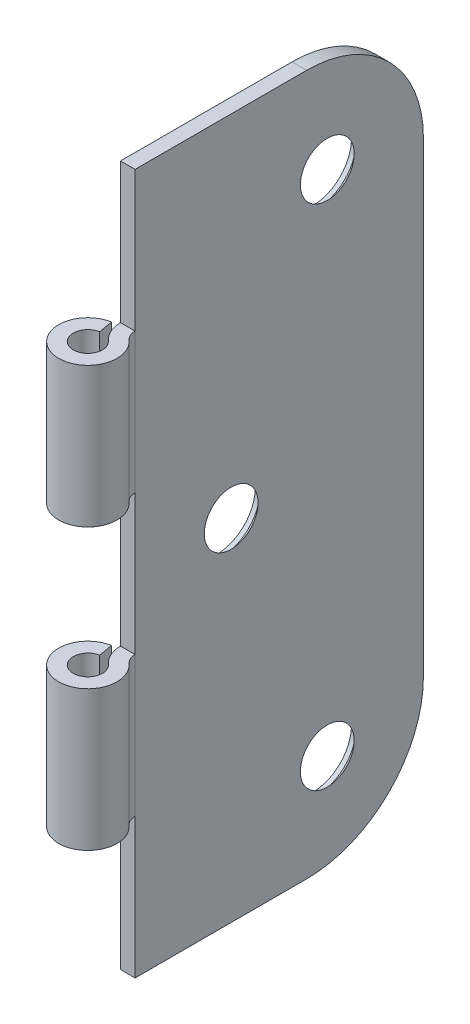
from build123d import *

# Parameters (mm, degrees)
BOSS_EXTRUDE1_DEPTH                       = 38.1
CUT_EXTRUDE1_DEPTH                        = 52.782682916
CUT_EXTRUDE1_DEPTH_BACK                   = 52.782682916
SKETCH3_W                                 = 6.724757914
SKETCH3_H                                 = 15.24
CSK_FOR_8_FLAT_HEAD_MACHINE_SCREW_2_COUNT = 2
CSK_FOR_8_FLAT_HEAD_MACHINE_SCREW_2_PITCH = 29.553945574
CSK_FOR_8_FLAT_HEAD_MACHINE_SCREW_3_COUNT = 2
CSK_FOR_8_FLAT_HEAD_MACHINE_SCREW_3_PITCH = 55.283171943
FILLET1_R                                 = 12.7


with BuildPart() as part:
    # Sketch2 → Boss-Extrude1 (new, symmetric)
    with BuildSketch(Plane(origin=(0, 0, 0), x_dir=(1, 0, 0), z_dir=(0, 1, 0))):
        with BuildLine():
            Line((1.5875, 34.925), (0, 34.925))
            Line((0, 34.925), (0, 3.549757914))
            ThreePointArc((0, 3.549757914), (0.2766348, 2.253569592), (1.058333333, 1.183252638))
            ThreePointArc((1.058333333, 1.183252638), (-0.435047689, -1.526725175), (-0.275666482, 1.563382308))
            Line((-0.275666482, 1.563382308), (-0.551332964, 3.126764616))
            ThreePointArc((-0.551332964, 3.126764616), (-0.870095378, -3.053450349), (2.116666667, 2.366505276))
            ThreePointArc((2.116666667, 2.366505276), (1.7258174, 2.901663753), (1.5875, 3.549757914))
            Line((1.5875, 3.549757914), (1.5875, 34.925))
        make_face()
    extrude(amount=BOSS_EXTRUDE1_DEPTH, both=True)

    # Sketch3 → Cut-Extrude1 (cut, two sides: drawn at the far end of the back side and taken through both)
    with BuildSketch(Plane(origin=(0, 0, 0), x_dir=(0, 0, -1), z_dir=(1, 0, 0)).offset(-CUT_EXTRUDE1_DEPTH_BACK)):
        with Locations((0.187378957, 30.48)):
            Rectangle(SKETCH3_W, SKETCH3_H)
        with Locations((0.187378957, 0)):
            Rectangle(SKETCH3_W, SKETCH3_H)
        with Locations((0.187378957, -30.48)):
            Rectangle(SKETCH3_W, SKETCH3_H)
    extrude(amount=CUT_EXTRUDE1_DEPTH + CUT_EXTRUDE1_DEPTH_BACK, mode=Mode.SUBTRACT)

    # Sketch4 → CSK for _8 Flat Head Machine Screw _100 (revolve, cut)
    with BuildSketch(Plane(origin=(0, -27.641585971, -24.466585971), x_dir=(0, 0, 1), z_dir=(0, 1, 0))):
        Polygon((0, 0), (0, 3.175), (2.2479, 3.175), (2.2479, 2.159767624), (4.2164, 0.508), (4.2164, 0), align=None)
    csk_for_8_flat_head_machine_screw_100 = revolve(axis=Axis((-6.35, -27.641585971, -24.466585971), (1, 0, 0)), mode=Mode.SUBTRACT)

    # CSK for _8 Flat Head Machine Screw _ 2: CSK for _8 Flat Head Machine Screw _100 ×2
    with Locations(*[Vector(0, 0.9352925788515203, 0.3538753904205162) * (i * CSK_FOR_8_FLAT_HEAD_MACHINE_SCREW_2_PITCH) for i in range(1, CSK_FOR_8_FLAT_HEAD_MACHINE_SCREW_2_COUNT)]):
        add(csk_for_8_flat_head_machine_screw_100, mode=Mode.SUBTRACT)

    # CSK for _8 Flat Head Machine Screw _ 3: CSK for _8 Flat Head Machine Screw _100 ×2
    with Locations(*[(0, i * CSK_FOR_8_FLAT_HEAD_MACHINE_SCREW_3_PITCH, 0) for i in range(1, CSK_FOR_8_FLAT_HEAD_MACHINE_SCREW_3_COUNT)]):
        add(csk_for_8_flat_head_machine_screw_100, mode=Mode.SUBTRACT)

    # Fillet1
    fillet1_edges = [part.edges().sort_by_distance(p)[0] for p in [
        (0.79375, 38.1, -34.925),
        (0.79375, -38.1, -34.925),
    ]]
    fillet(fillet1_edges, radius=FILLET1_R)


solid = part.part
